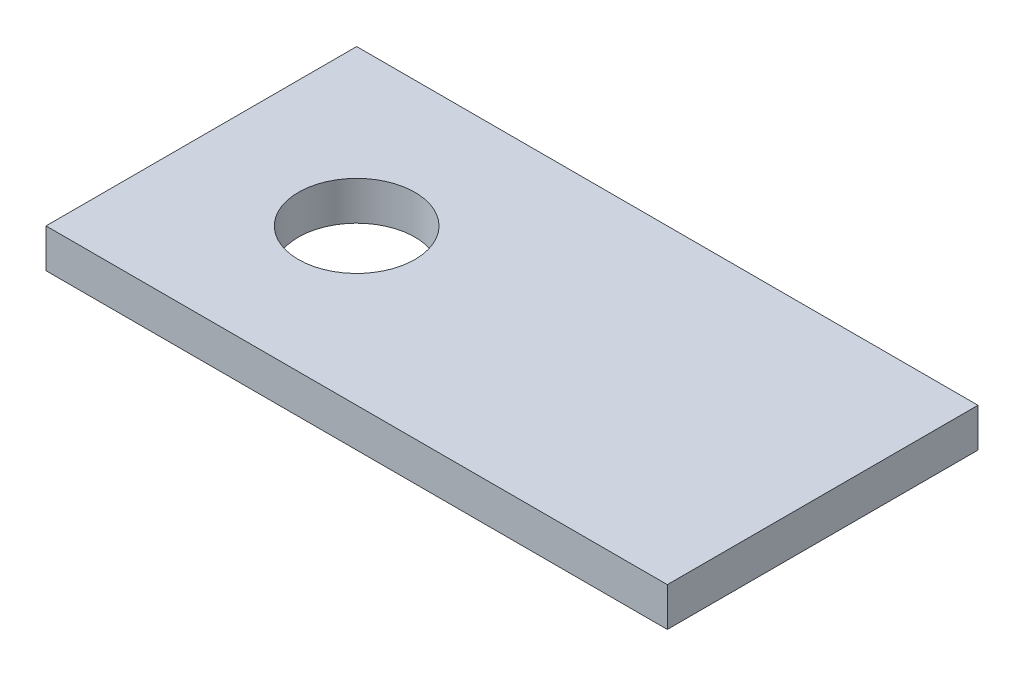
from build123d import *

# Parameters (mm, degrees)
SKETCH1_W           = 50.8
SKETCH1_H           = 25.4
BOSS_EXTRUDE1_DEPTH = 3.175
SKETCH2_R           = 4.7625
CUT_EXTRUDE1_DEPTH  = 3.175


with BuildPart() as part:
    # Sketch1 → Boss-Extrude1 (new body)
    with BuildSketch(Plane(origin=(0, 0, 0), x_dir=(1, 0, 0), z_dir=(0, 1, 0))):
        Rectangle(SKETCH1_W, SKETCH1_H)
    extrude(amount=BOSS_EXTRUDE1_DEPTH)

    # Sketch2 → Cut-Extrude1 (cut)
    with BuildSketch(Plane(origin=(0, 3.175, 0), x_dir=(1, 0, 0), z_dir=(0, 1, 0))):
        with Locations((-12.7, 0)):
            Circle(SKETCH2_R)
    extrude(amount=-CUT_EXTRUDE1_DEPTH, mode=Mode.SUBTRACT)


solid = part.part
